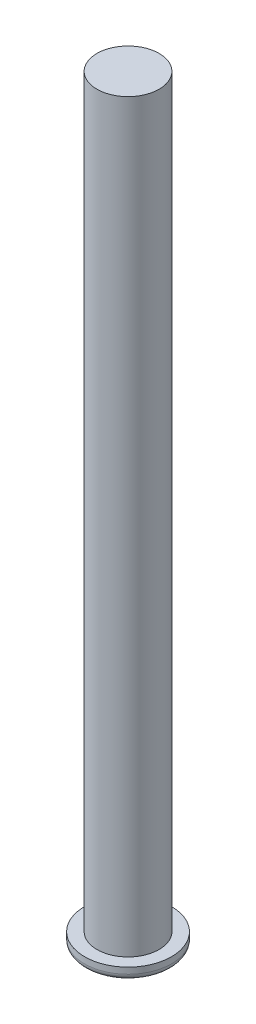
from build123d import *

# Parameters (mm, degrees)
SKETCH1_R           = 5
BOSS_EXTRUDE1_DEPTH = 120
SKETCH2_R           = 7
BOSS_EXTRUDE2_DEPTH = 2
FILLET1_R           = 1


with BuildPart() as part:
    # Sketch1 → Boss-Extrude1 (new body)
    with BuildSketch(Plane(origin=(0, 0, 0), x_dir=(1, 0, 0), z_dir=(0, 1, 0))):
        Circle(SKETCH1_R)
    extrude(amount=BOSS_EXTRUDE1_DEPTH)

    # Sketch2 → Boss-Extrude2 (add)
    with BuildSketch(Plane.XZ):
        Circle(SKETCH2_R)
    extrude(amount=BOSS_EXTRUDE2_DEPTH)

    # Fillet1
    fillet1_edges = [part.edges().sort_by_distance(p)[0] for p in [
        (-7, -2, 0),
    ]]
    fillet(fillet1_edges, radius=FILLET1_R)


solid = part.part
